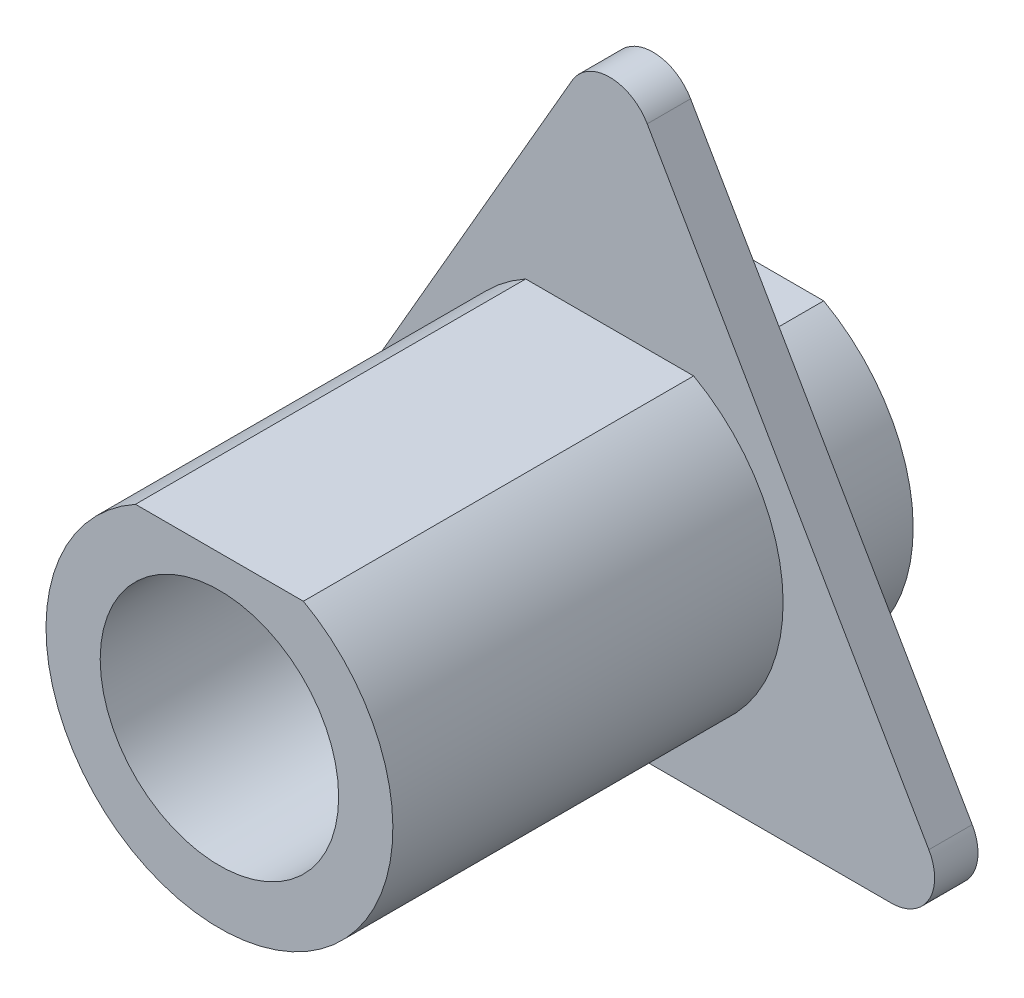
from build123d import *

# Parameters (mm, degrees)
EXTRUDE_1_DEPTH     = 12
EXTRUDE_2_DEPTH     = 1
SKETCH_2_R          = 2.75
CUT_EXTRUDE_1_DEPTH = 100


with BuildPart() as part:
    # 草图1 → 凸台-拉伸1 (new body)
    with BuildSketch(Plane.XY):
        with BuildLine():
            Line((-1.936491673, 3.5), (1.936491673, 3.5))
            ThreePointArc((1.936491673, 3.5), (0, -4), (-1.936491673, 3.5))
        make_face()
    extrude(amount=EXTRUDE_1_DEPTH)

    # 草图3 → 凸台-拉伸2 (add)
    with BuildSketch(Plane.XY.offset(3)):
        with BuildLine():
            Line((-6.495190528, -4.75), (6.495190528, -4.75))
            ThreePointArc((6.495190528, -4.75), (7.361215932, -4.25), (7.361215932, -3.25))
            Line((7.361215932, -3.25), (0.866025404, 8))
            ThreePointArc((0.866025404, 8), (0, 8.5), (-0.866025404, 8))
            Line((-0.866025404, 8), (-7.361215932, -3.25))
            ThreePointArc((-7.361215932, -3.25), (-7.361215932, -4.25), (-6.495190528, -4.75))
        make_face()
    extrude(amount=-EXTRUDE_2_DEPTH)

    # 草图2 → 切除-拉伸1 (cut)
    with BuildSketch(Plane.XY.offset(12)):
        Circle(SKETCH_2_R)
    extrude(amount=-CUT_EXTRUDE_1_DEPTH, mode=Mode.SUBTRACT)


solid = part.part
